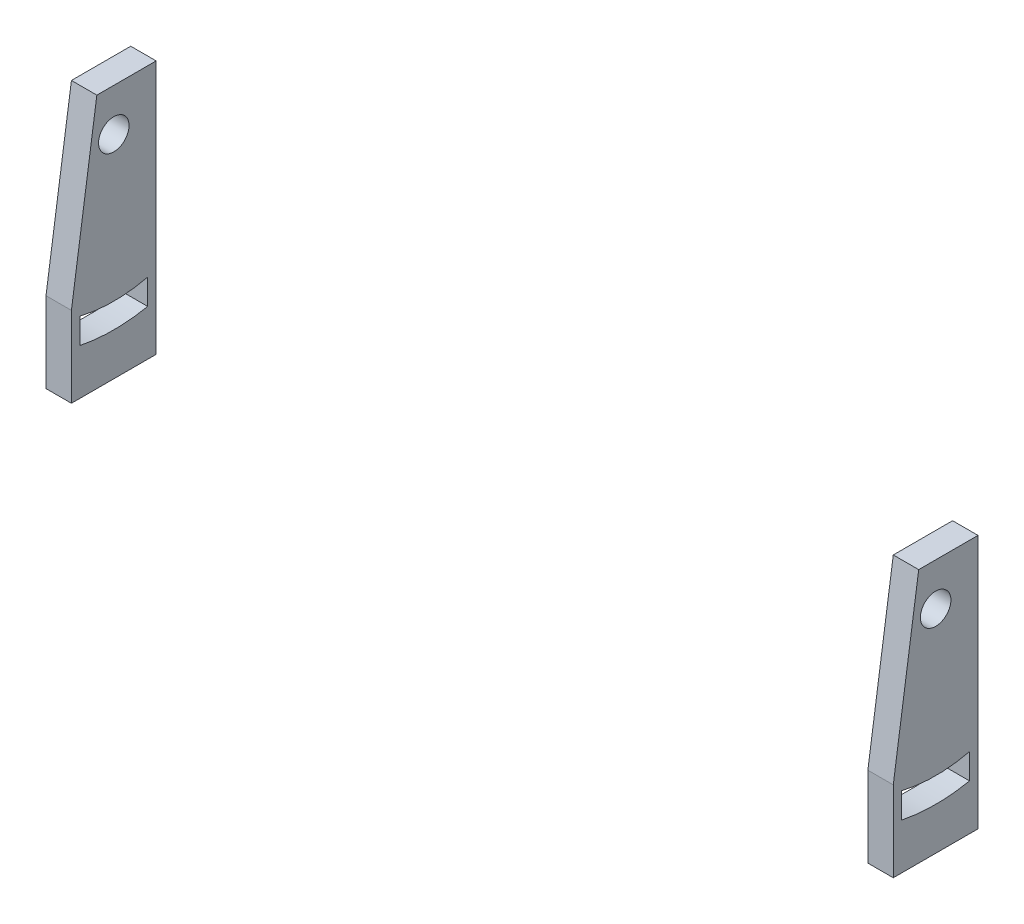
from build123d import *

# Parameters (mm, degrees)
SKETCH1_W           = 10
SKETCH1_H           = 30
BOSS_EXTRUDE1_DEPTH = 100
SKETCH2_W           = 94
SKETCH2_H           = 10
CUT_EXTRUDE1_DEPTH  = 100
SKETCH3_R           = 1.8
CUT_EXTRUDE2_DEPTH  = 100
CUT_EXTRUDE3_DEPTH  = 100
CUT_EXTRUDE5_DEPTH  = 100


with BuildPart() as part:
    # Sketch1 → Boss-Extrude1 (new body)
    with BuildSketch(Plane(origin=(0, 0, 0), x_dir=(0, 0, -1), z_dir=(1, 0, 0))):
        with Locations((-6.908426326, 1.532136894)):
            Rectangle(SKETCH1_W, SKETCH1_H)
    extrude(amount=BOSS_EXTRUDE1_DEPTH)

    # Sketch2 → Cut-Extrude1 (cut)
    with BuildSketch(Plane(origin=(0, 16.532136894, 0), x_dir=(1, 0, 0), z_dir=(0, 1, 0))):
        with Locations((50, -6.908426326)):
            Rectangle(SKETCH2_W, SKETCH2_H)
    extrude(amount=-CUT_EXTRUDE1_DEPTH, mode=Mode.SUBTRACT)

    # Sketch3 → Cut-Extrude2 (cut)
    with BuildSketch(Plane(origin=(100, 0, 0), x_dir=(0, 0, -1), z_dir=(1, 0, 0))):
        with Locations((-6.908426326, 11.532136894)):
            Circle(SKETCH3_R)
    extrude(amount=-CUT_EXTRUDE2_DEPTH, mode=Mode.SUBTRACT)

    # Sketch4 → Cut-Extrude3 (cut)
    with BuildSketch(Plane(origin=(100, 0, 0), x_dir=(0, 0, -1), z_dir=(1, 0, 0))):
        with BuildLine():
            Line((-10.908426326, -5.063781049), (-10.908426326, -8.063781049))
            ThreePointArc((-10.908426326, -8.063781049), (-6.908426326, -8.467863106), (-2.908426326, -8.063781049))
            Line((-2.908426326, -8.063781049), (-2.910860918, -5.064367653))
            ThreePointArc((-2.910860918, -5.064367653), (-6.909678458, -5.539022727), (-10.908426326, -5.063781049))
        make_face()
    extrude(amount=-CUT_EXTRUDE3_DEPTH, mode=Mode.SUBTRACT)

    # Sketch5 → Cut-Extrude5 (cut)
    with BuildSketch(Plane.ZY):
        Polygon((8.908426326, 16.532136894), (11.908426326, -3.967863106), (11.908426326, 16.532136894), align=None)
    extrude(amount=-CUT_EXTRUDE5_DEPTH, mode=Mode.SUBTRACT)


solid = part.part
